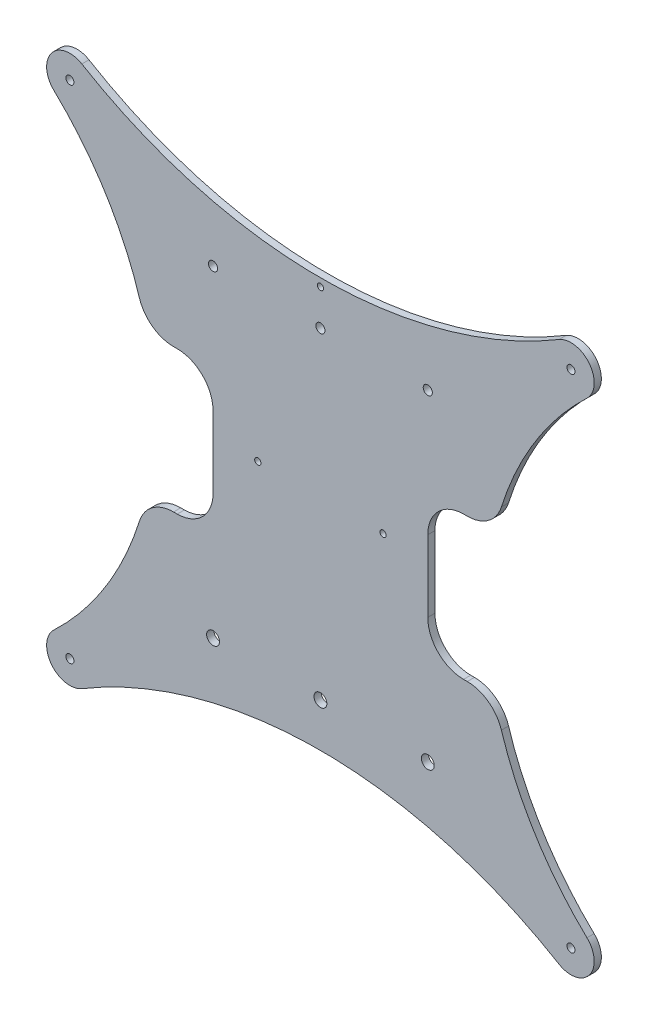
from build123d import *

# Parameters (mm, degrees)
SKETCH_1_R          = 2.55
SKETCH_1_R_2        = 3.6
SKETCH_1_R_3        = 2.25
SKETCH_1_R_4        = 1.75
EXTRUDE_1_DEPTH     = 4
SKETCH_2_W          = 60.730368491
SKETCH_2_H          = 80
CUT_EXTRUDE_1_DEPTH = 10
FILLET_1_R          = 20


with BuildPart() as part:
    # 草图1 → 凸台-拉伸1 (new body)
    with BuildSketch(Plane.XY):
        with BuildLine():
            ThreePointArc((-133.333333333, 151.160446029), (-150.358269338, 147.855332986), (-148.948414541, 130.569948187))
            ThreePointArc((-148.948414541, 130.569948187), (-92.849538953, 0), (-148.948414541, -130.569948187))
            ThreePointArc((-148.948414541, -130.569948187), (-150.358269338, -147.855332986), (-133.333333333, -151.160446029))
            ThreePointArc((-133.333333333, -151.160446029), (0, -114.369366599), (133.333333333, -151.160446029))
            ThreePointArc((133.333333333, -151.160446029), (150.358269338, -147.855332986), (148.948414541, -130.569948187))
            ThreePointArc((148.948414541, -130.569948187), (92.849538953, 0), (148.948414541, 130.569948187))
            ThreePointArc((148.948414541, 130.569948187), (150.358269338, 147.855332986), (133.333333333, 151.160446029))
            ThreePointArc((133.333333333, 151.160446029), (0, 114.369366599), (-133.333333333, 151.160446029))
        make_face()
        with Locations((0, 90)):
            Circle(SKETCH_1_R, mode=Mode.SUBTRACT)
        with Locations((0, -90)):
            Circle(SKETCH_1_R_2, mode=Mode.SUBTRACT)
        with Locations((60, 90)):
            Circle(SKETCH_1_R, mode=Mode.SUBTRACT)
        with Locations((60, -90)):
            Circle(SKETCH_1_R_2, mode=Mode.SUBTRACT)
        with Locations((-60, 90)):
            Circle(SKETCH_1_R, mode=Mode.SUBTRACT)
        with Locations((-60, -90)):
            Circle(SKETCH_1_R_2, mode=Mode.SUBTRACT)
        with Locations((-140, 140)):
            Circle(SKETCH_1_R_3, mode=Mode.SUBTRACT)
        with Locations((140, 140)):
            Circle(SKETCH_1_R_3, mode=Mode.SUBTRACT)
        with Locations((-140, -140)):
            Circle(SKETCH_1_R_3, mode=Mode.SUBTRACT)
        with Locations((140, -140)):
            Circle(SKETCH_1_R_3, mode=Mode.SUBTRACT)
        with Locations((-35, 8)):
            Circle(SKETCH_1_R_4, mode=Mode.SUBTRACT)
        with Locations((35, 8)):
            Circle(SKETCH_1_R_4, mode=Mode.SUBTRACT)
        with Locations((0, 110)):
            Circle(SKETCH_1_R_4, mode=Mode.SUBTRACT)
    extrude(amount=EXTRUDE_1_DEPTH)

    # 草图2 → 切除-拉伸1 (cut)
    with BuildSketch(Plane.XY.offset(4)):
        with Locations((-90.365184246, 0)):
            Rectangle(SKETCH_2_W, SKETCH_2_H)
        with Locations((90.365184246, 0)):
            Rectangle(SKETCH_2_W, SKETCH_2_H)
    extrude(amount=-CUT_EXTRUDE_1_DEPTH, mode=Mode.SUBTRACT)

    # 圆角1
    fillet_1_edges = [part.edges().sort_by_distance(p)[0] for p in [
        (60, -40, 2),
        (60, 40, 2),
        (-97.350251205, -40, 2),
        (-97.350251205, 40, 2),
        (-60, 40, 2),
        (-60, -40, 2),
        (97.350251205, 40, 2),
        (97.350251205, -40, 2),
    ]]
    fillet(fillet_1_edges, radius=FILLET_1_R)


solid = part.part
